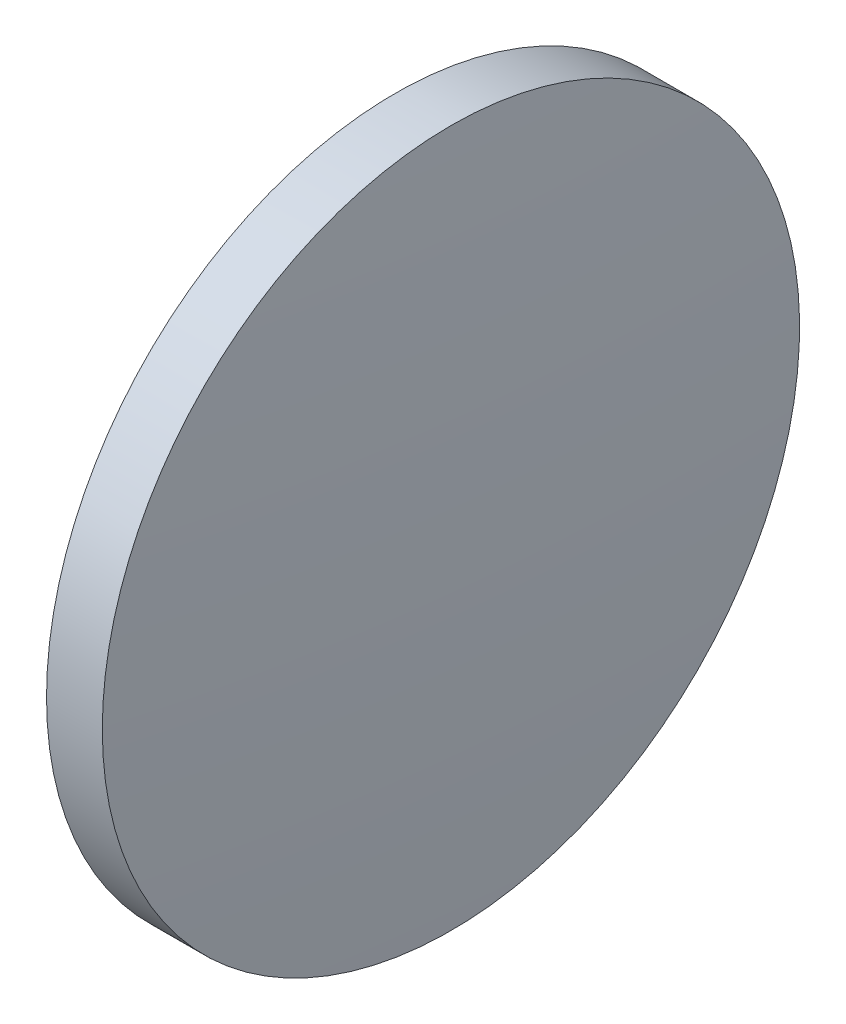
from build123d import *


with BuildPart() as part:
    # 草图1 → 旋转1 (revolve)
    with BuildSketch(Plane.XY):
        with BuildLine():
            Line((379.29467545, 209.041396646), (379.29467545, 221.541396646))
            Line((379.29467545, 221.541396646), (381.29467545, 221.541396646))
            ThreePointArc((381.29467545, 221.541396646), (381.579653511, 215.294283979), (381.67467545, 209.041396646))
            Line((381.67467545, 209.041396646), (379.29467545, 209.041396646))
        make_face()
    revolve(axis=Axis((376.929059547, 209.041396646, 0), (1, 0, 0)))


solid = part.part
